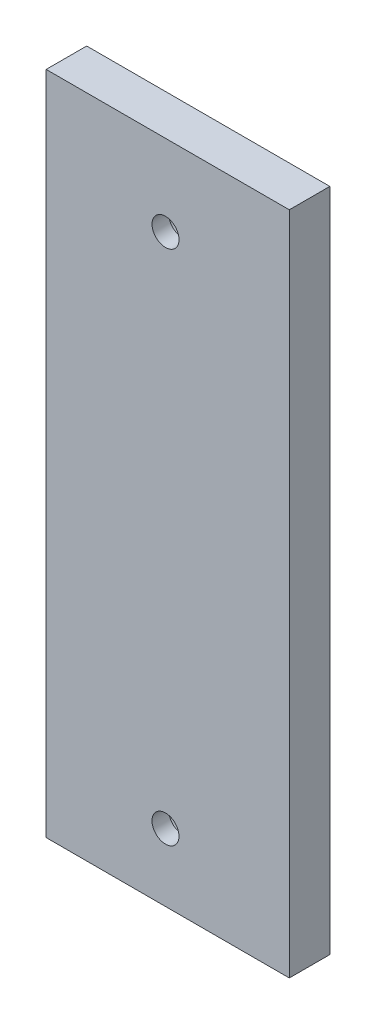
from build123d import *

# Parameters (mm, degrees)
SKETCH1_W           = 40
SKETCH1_H           = 96.5
BOSS_EXTRUDE1_DEPTH = 4
CUT_EXTRUDE3_DEPTH  = 20
SKETCH5_R           = 2
CUT_EXTRUDE5_DEPTH  = 10
SKETCH6_W           = 2
SKETCH6_H           = 96.5
CUT_EXTRUDE6_DEPTH  = 10
SKETCH7_W           = 36
SKETCH7_H           = 96.5
SKETCH7_R           = 2
BOSS_EXTRUDE2_DEPTH = 2
CUT_EXTRUDE7_DEPTH  = 97.5
SKETCH8_R           = 4.25
SKETCH8_R_2         = 2
CUT_EXTRUDE8_DEPTH  = 3.5
CUT_EXTRUDE10_DEPTH = 122
SKETCH10_W          = 36
SKETCH10_H          = 6
BOSS_EXTRUDE3_DEPTH = 2


with BuildPart() as part:
    # Sketch1 → Boss-Extrude1 (new body)
    with BuildSketch(Plane.XY):
        with Locations((0.330243162, -38.25)):
            Rectangle(SKETCH1_W, SKETCH1_H)
    extrude(amount=BOSS_EXTRUDE1_DEPTH)

    # Sketch3 → Cut-Extrude3 (cut)
    with BuildSketch(Plane.XZ.offset(86.5)):
        Polygon((-12.106417754, 4), (-10.650536835, 0), (-7.858578609, 0), (-11.858578609, 4), align=None)
        Polygon((11.858580346, 4), (7.858579777, 0), (10.650537342, 0), (12.106418599, 4), align=None)
    extrude(amount=-CUT_EXTRUDE3_DEPTH, mode=Mode.SUBTRACT)

    # Sketch5 → Cut-Extrude5 (cut)
    with BuildSketch(Plane.XY.offset(4)):
        Circle(SKETCH5_R)
        with Locations((0, -76.5)):
            Circle(SKETCH5_R)
    extrude(amount=-CUT_EXTRUDE5_DEPTH, mode=Mode.SUBTRACT)

    # Sketch6 → Cut-Extrude6 (cut)
    with BuildSketch(Plane.XY.offset(4)):
        with Locations((-18.669756838, -38.25)):
            Rectangle(SKETCH6_W, SKETCH6_H)
        with Locations((19.330243162, -38.25)):
            Rectangle(SKETCH6_W, SKETCH6_H)
    extrude(amount=-CUT_EXTRUDE6_DEPTH, mode=Mode.SUBTRACT)

    # Sketch7 → Boss-Extrude2 (add)
    with BuildSketch(Plane.XY.offset(4)):
        with Locations((0.330243162, -38.25)):
            Rectangle(SKETCH7_W, SKETCH7_H)
        with Locations((0, -76.5)):
            Circle(SKETCH7_R, mode=Mode.SUBTRACT)
        Circle(SKETCH7_R, mode=Mode.SUBTRACT)
    extrude(amount=BOSS_EXTRUDE2_DEPTH)

    # Sketch4 → Cut-Extrude7 (cut, through all)
    with BuildSketch(Plane(origin=(0, 10, 0), x_dir=(1, 0, 0), z_dir=(0, 1, 0))):
        Polygon((-11.858578609, -4), (-7.858578609, 0), (-10.650536835, 0), (-12.106417754, -4), align=None)
        Polygon((10.650537342, 0), (7.858579777, 0), (11.858580346, -4), (12.106418599, -4), align=None)
    extrude(amount=-CUT_EXTRUDE7_DEPTH, mode=Mode.SUBTRACT)

    # Sketch8 → Cut-Extrude8 (cut)
    with BuildSketch(Plane(origin=(0, 0, 0), x_dir=(-1, 0, 0), z_dir=(0, 0, -1))):
        Circle(SKETCH8_R)
        Circle(SKETCH8_R_2, mode=Mode.SUBTRACT)
        with Locations((0, -76.5)):
            Circle(SKETCH8_R)
        with Locations((0, -76.5)):
            Circle(SKETCH8_R_2, mode=Mode.SUBTRACT)
    extrude(amount=-CUT_EXTRUDE8_DEPTH, mode=Mode.SUBTRACT)

    # Sketch9 → Cut-Extrude10 (cut)
    with BuildSketch(Plane(origin=(0, 10, 0), x_dir=(1, 0, 0), z_dir=(0, 1, 0))):
        Polygon((-10.790578344, 0.2), (-7.375735897, 0.2), (-11.775735897, -4.2), (-12.392047354, -4.2), align=None)
        Polygon((7.375737016, 0.2), (10.790578839, 0.2), (12.392048222, -4.2), (11.775737642, -4.2), align=None)
    extrude(amount=-CUT_EXTRUDE10_DEPTH, mode=Mode.SUBTRACT)

    # Sketch10 → Boss-Extrude3 (add)
    with BuildSketch(Plane(origin=(0, 10, 0), x_dir=(1, 0, 0), z_dir=(0, 1, 0))):
        with Locations((0.330243162, -3)):
            Rectangle(SKETCH10_W, SKETCH10_H)
    extrude(amount=BOSS_EXTRUDE3_DEPTH)


solid = part.part
